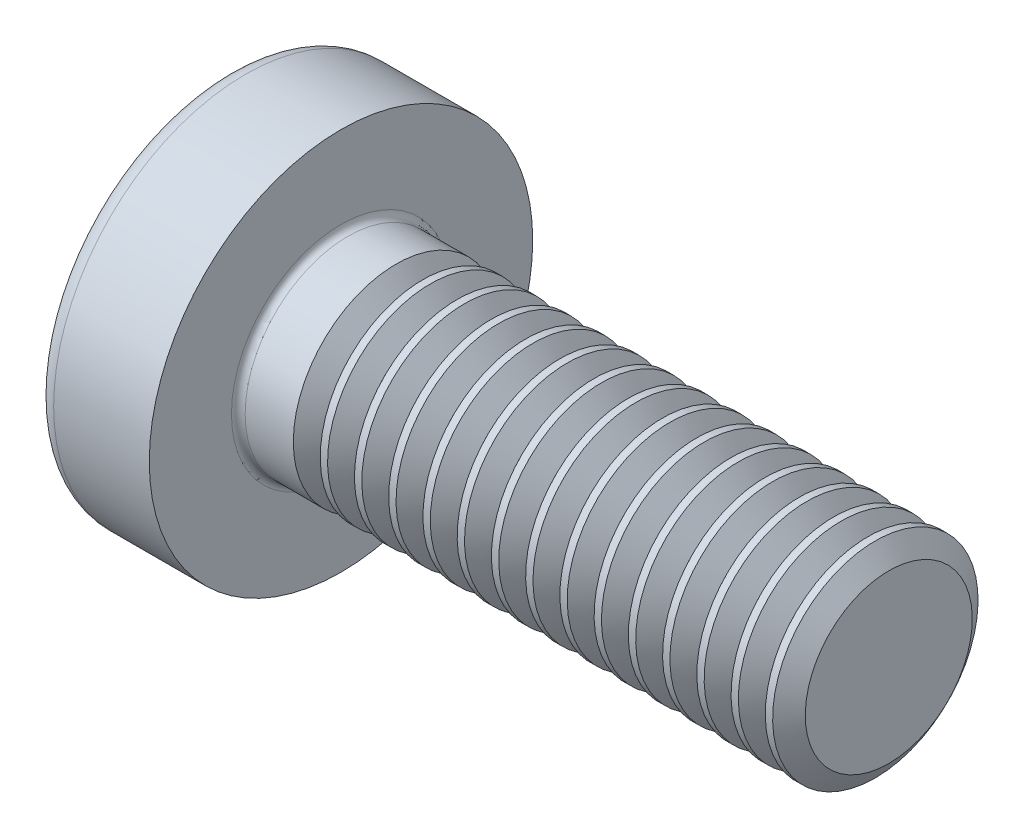
from build123d import *

# Parameters (mm, degrees)
FILLET1_R       = 0.1
SKETCH3_W       = 0.74
SKETCH3_H       = 2.8
SKETCH4_W       = 0.74
SKETCH4_H       = 1.054964664
RECPAT_COUNT    = 2
RECPAT_ANGLE    = 90
THDSCHPAT_COUNT = 15
THDSCHPAT_PITCH = 0.5


with BuildPart() as part:
    # BodySke → Base-Revolve (revolve)
    with BuildSketch(Plane.XY, mode=Mode.PRIVATE) as base_revolve_sk:
        with BuildLine():
            Line((2.4, 1.5), (2.4, 2.8))
            Line((2.4, 2.8), (1.003501533, 2.8))
            ThreePointArc((1.003501533, 2.8), (0.873295971, 2.76653015), (0.775371599, 2.674418605))
            ThreePointArc((0.775371599, 2.674418605), (0.197753546, 1.392274756), (0, 0))
            Line((0, 0), (10.4, 0))
            Line((10.4, 0), (10.4, 1.5))
            Line((10.4, 1.5), (2.4, 1.5))
        make_face()
    revolve(base_revolve_sk.sketch.rotate(Axis((-25.4, 0, 0), (1, 0, 0)), 90), axis=Axis((-25.4, 0, 0), (1, 0, 0)))  # turned: the seam where the file's is

    # Fillet1
    fillet1_edges = [part.edges().sort_by_distance(p)[0] for p in [
        (2.4, 0, -1.5),
    ]]
    fillet(fillet1_edges, radius=FILLET1_R)

    # Sketch3 → Recess section 0
    with BuildSketch(Plane(origin=(0, 0, 0), x_dir=(0, 0, -1), z_dir=(1, 0, 0))):
        Rectangle(SKETCH3_W, SKETCH3_H)
    # Sketch4 → Recess section 1
    with BuildSketch(Plane(origin=(1.75, 0, 0), x_dir=(0, 0, -1), z_dir=(1, 0, 0))):
        Rectangle(SKETCH4_W, SKETCH4_H)
    recess = loft(mode=Mode.SUBTRACT)

    # RecPat: Recess ×2 about axis
    recpat_axis = Axis((0, 0, 0), (1, 0, 0))
    for i in range(1, RECPAT_COUNT):
        add(recess.rotate(recpat_axis, i * RECPAT_ANGLE / (RECPAT_COUNT - 1)), mode=Mode.SUBTRACT)

    # RecCorSke → RecessCore (revolve, cut)
    with BuildSketch(Plane.XY, mode=Mode.PRIVATE) as recesscore_sk:
        Polygon((0, 0), (0, 0.678371921), (1.75, 0.556), (1.930655351, 0), align=None)
    revolve(recesscore_sk.sketch.rotate(Axis((-3.175, 0, 0), (1, 0, 0)), 90), axis=Axis((-3.175, 0, 0), (1, 0, 0)), mode=Mode.SUBTRACT)  # turned: the seam where the file's is

    # ThdSchSke → ThreadSchematic (revolve, cut)
    with BuildSketch(Plane.XY, mode=Mode.PRIVATE) as threadschematic_sk:
        Polygon((3.4, -1.2195), (3.203591786, -1.5), (3.203591786, -1.875), (3.596408214, -1.875), (3.596408214, -1.5), align=None)
    threadschematic = revolve(threadschematic_sk.sketch.rotate(Axis((-3.175, 0, 0), (1, 0, 0)), 270), axis=Axis((-3.175, 0, 0), (1, 0, 0)), mode=Mode.SUBTRACT)  # turned: the seam where the file's is

    # ThdSchPat: ThreadSchematic ×15
    with Locations(*[(i * THDSCHPAT_PITCH, 0, 0) for i in range(1, THDSCHPAT_COUNT)]):
        add(threadschematic, mode=Mode.SUBTRACT)


solid = part.part
